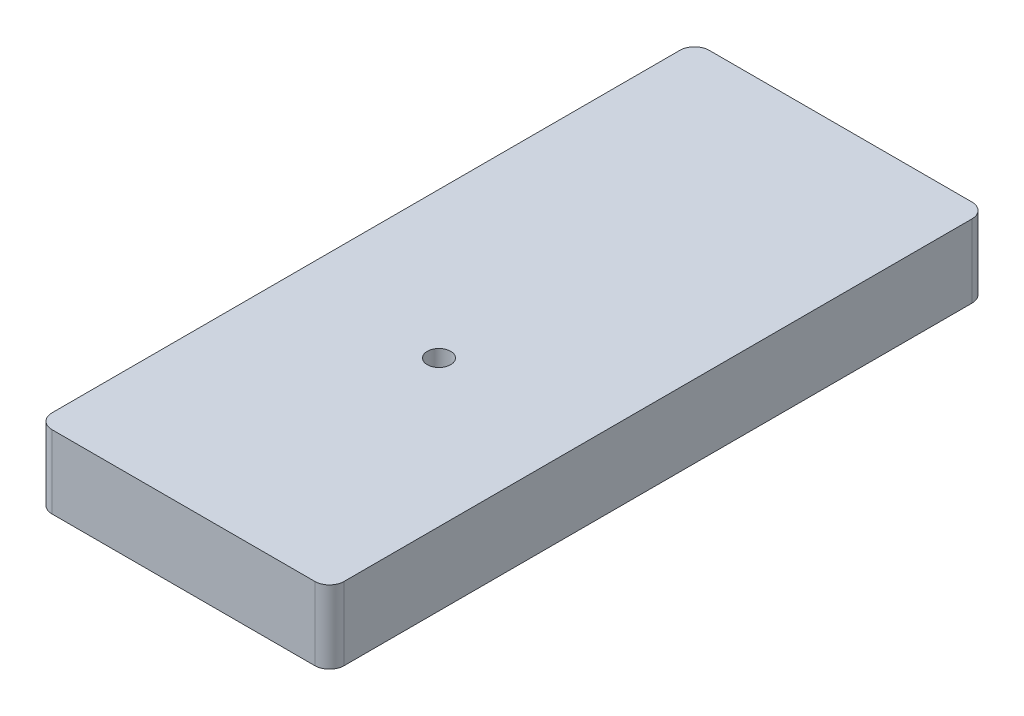
from build123d import *

# Parameters (mm, degrees)
ESQUISSE1_R             = 1.6
EXTRUSION1_DEPTH        = 10
ESQUISSE2_R             = 1.1
ENL_V_MAT_EXTRU_1_DEPTH = 4


with BuildPart() as part:
    # Esquisse1 → Extrusion1 (new body)
    with BuildSketch(Plane(origin=(0, 0, 0), x_dir=(1, 0, 0), z_dir=(0, 1, 0))):
        with BuildLine():
            Line((13, 2), (13, 88))
            ThreePointArc((13, 88), (13.585786438, 89.414213562), (15, 90))
            Line((15, 90), (51, 90))
            ThreePointArc((51, 90), (52.414213562, 89.414213562), (53, 88))
            Line((53, 88), (53, 2))
            ThreePointArc((53, 2), (52.414213562, 0.585786438), (51, 0))
            Line((51, 0), (15, 0))
            ThreePointArc((15, 0), (13.585786438, 0.585786438), (13, 2))
        make_face()
        with Locations(Location((33, 35, 0), (0, 0, 270))):  # turned: the seam where the file's is
            Circle(ESQUISSE1_R, mode=Mode.SUBTRACT)
    extrude(amount=EXTRUSION1_DEPTH)

    # Esquisse2 → Enlèv. mat.-Extru.1 (cut)
    with BuildSketch(Plane.XZ):
        with Locations(Location((21, -7, 0), (0, 0, 90))):  # turned: the seam where the file's is
            Circle(ESQUISSE2_R)
        with Locations(Location((21, -23, 0), (0, 0, 90))):  # turned: the seam where the file's is
            Circle(ESQUISSE2_R)
        with BuildLine():
            Line((41, -82.7372583), (41, -81.2627417))
            ThreePointArc((41, -81.2627417), (41, -79), (38.7372583, -79))
            Line((38.7372583, -79), (27.2627417, -79))
            ThreePointArc((27.2627417, -79), (25, -79), (25, -81.2627417))
            Line((25, -81.2627417), (25, -82.7372583))
            ThreePointArc((25, -82.7372583), (25, -85), (27.2627417, -85))
            Line((27.2627417, -85), (38.7372583, -85))
            ThreePointArc((38.7372583, -85), (41, -85), (41, -82.7372583))
        make_face()
        with BuildLine():
            Line((45.7372583, -49.5), (44.2627417, -49.5))
            ThreePointArc((44.2627417, -49.5), (42, -49.5), (42, -51.7627417))
            Line((42, -51.7627417), (42, -67.2372583))
            ThreePointArc((42, -67.2372583), (42, -69.5), (44.2627417, -69.5))
            Line((44.2627417, -69.5), (45.7372583, -69.5))
            ThreePointArc((45.7372583, -69.5), (48, -69.5), (48, -67.2372583))
            Line((48, -67.2372583), (48, -51.7627417))
            ThreePointArc((48, -51.7627417), (48, -49.5), (45.7372583, -49.5))
        make_face()
        with BuildLine():
            Line((24, -67.2372583), (24, -51.7627417))
            ThreePointArc((24, -51.7627417), (24, -49.5), (21.7372583, -49.5))
            Line((21.7372583, -49.5), (20.2627417, -49.5))
            ThreePointArc((20.2627417, -49.5), (18, -49.5), (18, -51.7627417))
            Line((18, -51.7627417), (18, -67.2372583))
            ThreePointArc((18, -67.2372583), (18, -69.5), (20.2627417, -69.5))
            Line((20.2627417, -69.5), (21.7372583, -69.5))
            ThreePointArc((21.7372583, -69.5), (24, -69.5), (24, -67.2372583))
        make_face()
    extrude(amount=-ENL_V_MAT_EXTRU_1_DEPTH, mode=Mode.SUBTRACT)


solid = part.part
